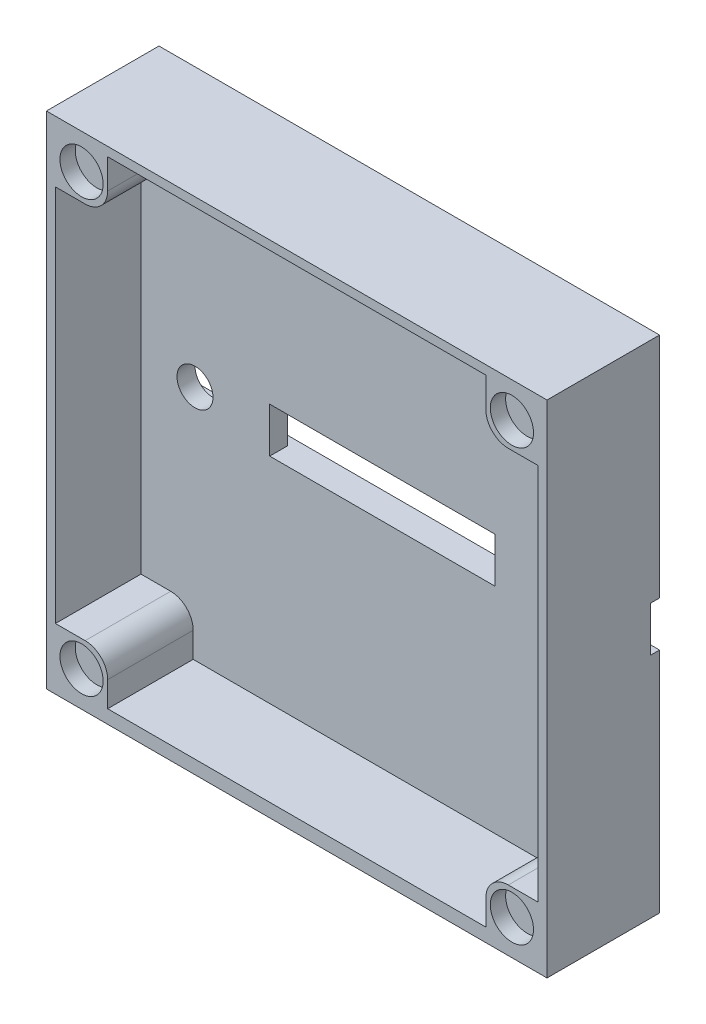
from build123d import *

# Parameters (mm, degrees)
SKICA1_W                 = 55.6
SKICA1_H                 = 55.6
P_IDAT_VYSUNUT_M2_DEPTH  = 3
SKICA4_W                 = 25
SKICA4_H                 = 5
ODEBRAT_VYSUNUT_M1_DEPTH = 2
SKICA5_W                 = 55.6
SKICA5_H                 = 5
ODEBRAT_VYSUNUT_M3_DEPTH = 1
SKICA14_W                = 53.6
SKICA14_H                = 1.5
P_IDAT_VYSUNUT_M9_DEPTH  = 9.5
SKICA17_R                = 2
ODEBRAT_VYSUNUT_M8_DEPTH = 4
SKICA19_W                = 6.8
SKICA19_H                = 6.8
P_IDAT_VYSUNUT_M10_DEPTH = 12.5
SKICA20_R                = 2.4
ODEBRAT_VYSUNUT_M9_DEPTH = 1.7
ZAOBLIT1_R               = 2.5


with BuildPart() as part:
    # Skica1 → Přidat vysunutím2 (new body)
    with BuildSketch(Plane.XY):
        Rectangle(SKICA1_W, SKICA1_H)
    extrude(amount=P_IDAT_VYSUNUT_M2_DEPTH)

    # Skica4 → Odebrat vysunutím1 (cut)
    with BuildSketch(Plane.XY.offset(3)):
        Rectangle(SKICA4_W, SKICA4_H)
    extrude(amount=-ODEBRAT_VYSUNUT_M1_DEPTH, mode=Mode.SUBTRACT)

    # Skica5 → Odebrat vysunutím3 (cut)
    with BuildSketch(Plane(origin=(0, 0, 0), x_dir=(-1, 0, 0), z_dir=(0, 0, -1))):
        Rectangle(SKICA5_W, SKICA5_H)
    extrude(amount=-ODEBRAT_VYSUNUT_M3_DEPTH, mode=Mode.SUBTRACT)

    # Skica14 → Přidat vysunutím9 (add)
    with BuildSketch(Plane.XY.offset(3)):
        Polygon((27.8, 27.8), (-27.8, 27.8), (-27.8, -27.8), (-26.8, -27.8), (-26.8, -26.8), (-26.8, -26.3), (-26.8, 26.8), (26.8, 26.8), (26.8, -26.3), (26.8, -27.8), (27.8, -27.8), align=None)
        with Locations((0, -27.05)):
            Rectangle(SKICA14_W, SKICA14_H)
    extrude(amount=P_IDAT_VYSUNUT_M9_DEPTH)

    # Skica17 → Odebrat vysunutím8 (cut)
    with BuildSketch(Plane(origin=(0, 0, 1), x_dir=(-1, 0, 0), z_dir=(0, 0, -1))):
        with Locations((-20.8, 0)):
            Circle(SKICA17_R)
        with Locations((20.8, 0)):
            Circle(SKICA17_R)
    extrude(amount=-ODEBRAT_VYSUNUT_M8_DEPTH, mode=Mode.SUBTRACT)

    # Skica19 → Přidat vysunutím10 (add)
    with BuildSketch(Plane(origin=(0, 0, 0), x_dir=(-1, 0, 0), z_dir=(0, 0, -1))):
        with Locations((-24.4, 24.4)):
            Rectangle(SKICA19_W, SKICA19_H)
        with Locations((24.4, 24.4)):
            Rectangle(SKICA19_W, SKICA19_H)
        with Locations((-24.4, -24.4)):
            Rectangle(SKICA19_W, SKICA19_H)
        with Locations((24.4, -24.4)):
            Rectangle(SKICA19_W, SKICA19_H)
    extrude(amount=-P_IDAT_VYSUNUT_M10_DEPTH)

    # Skica20 → Odebrat vysunutím9 (cut)
    with BuildSketch(Plane.XY.offset(12.5)):
        with Locations((-23.9, -23.9)):
            Circle(SKICA20_R)
        with Locations((-23.9, 23.9)):
            Circle(SKICA20_R)
        with Locations((23.900280565, 23.9)):
            Circle(SKICA20_R)
        with Locations((23.900280565, -23.9)):
            Circle(SKICA20_R)
    extrude(amount=-ODEBRAT_VYSUNUT_M9_DEPTH, mode=Mode.SUBTRACT)

    # Zaoblit1
    zaoblit1_edges = [part.edges().sort_by_distance(p)[0] for p in [
        (-21, 21, 7.75),
        (21, -21, 7.75),
        (-21, -21, 7.75),
        (21, 21, 7.75),
    ]]
    fillet(zaoblit1_edges, radius=ZAOBLIT1_R)


solid = part.part
